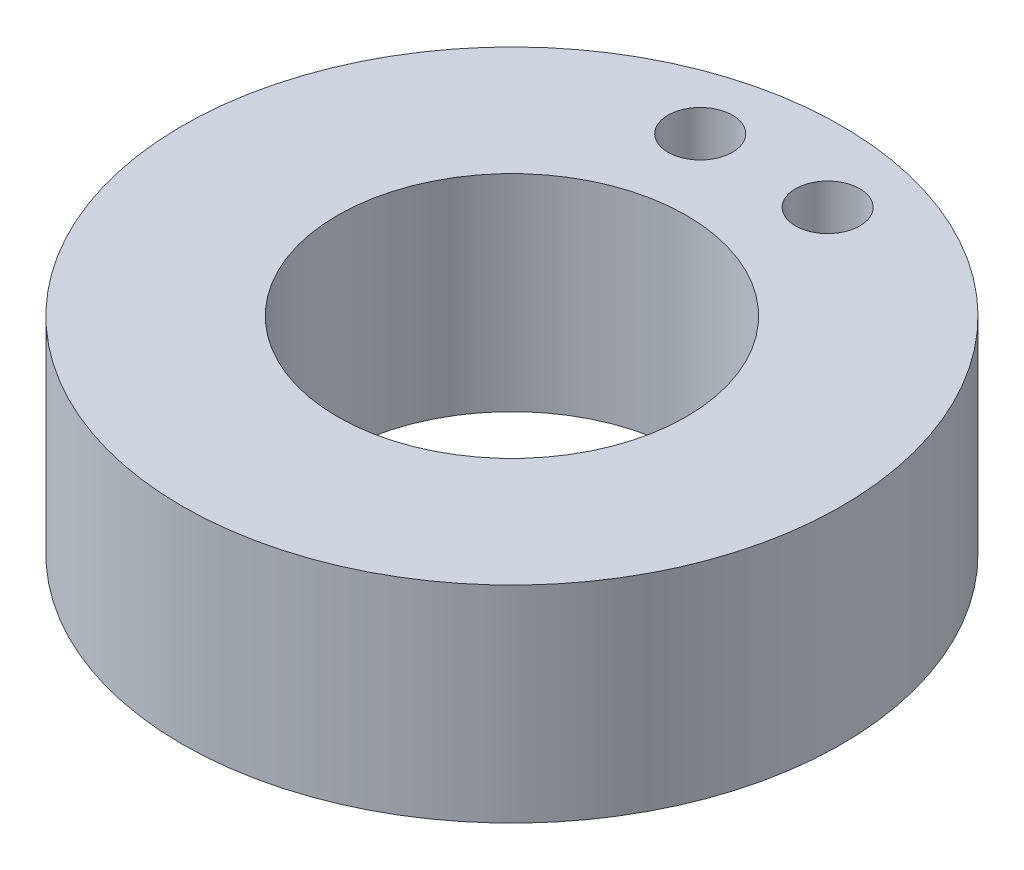
from build123d import *

# Parameters (mm, degrees)
SKETCH1_R           = 16.2433
SKETCH1_R_2         = 8.5979
BOSS_EXTRUDE1_DEPTH = 10.16
SKETCH2_R           = 1.5875
CUT_EXTRUDE2_DEPTH  = 11.16


with BuildPart() as part:
    # Sketch1 → Boss-Extrude1 (new body)
    with BuildSketch(Plane(origin=(0, 0, 0), x_dir=(1, 0, 0), z_dir=(0, 1, 0))):
        Circle(SKETCH1_R)
        Circle(SKETCH1_R_2, mode=Mode.SUBTRACT)
    extrude(amount=BOSS_EXTRUDE1_DEPTH)

    # Sketch2 → Cut-Extrude2 (cut, through all)
    with BuildSketch(Plane(origin=(0, 10.16, 0), x_dir=(1, 0, 0), z_dir=(0, 1, 0))):
        with Locations((-3.140315604, 12.4206)):
            Circle(SKETCH2_R)
        with Locations((3.140315604, 12.4206)):
            Circle(SKETCH2_R)
    extrude(amount=-CUT_EXTRUDE2_DEPTH, mode=Mode.SUBTRACT)


solid = part.part
